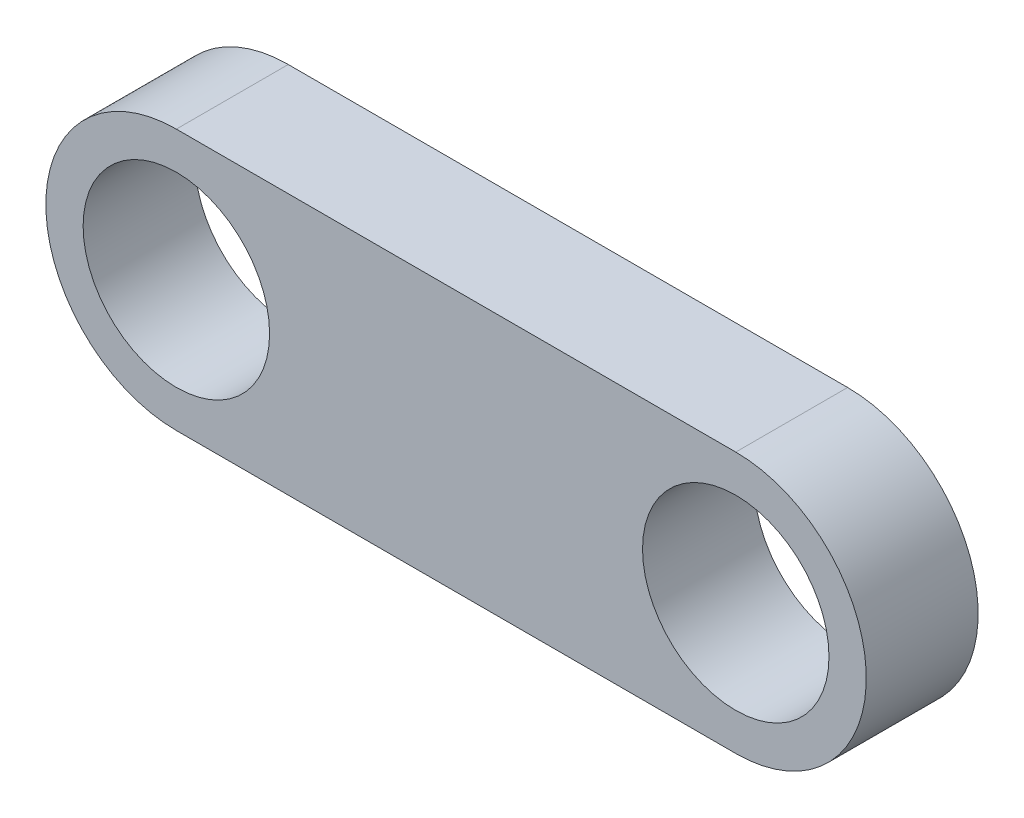
from build123d import *

# Parameters (mm, degrees)
BOSS_EXTRUDE1_DEPTH = 6
SKETCH2_R           = 5
CUT_EXTRUDE1_DEPTH  = 6
SCALE1_SCALE        = 0.3


with BuildPart() as part:
    # Sketch1 → Boss-Extrude1 (new body)
    with BuildSketch(Plane.XY):
        with BuildLine():
            Line((-13.846153846, 7), (16.153846154, 7))
            ThreePointArc((16.153846154, 7), (23.153846154, 0), (16.153846154, -7))
            Line((16.153846154, -7), (-13.846153846, -7))
            ThreePointArc((-13.846153846, -7), (-20.846153846, 0), (-13.846153846, 7))
        make_face()
    extrude(amount=BOSS_EXTRUDE1_DEPTH)

    # Sketch2 → Cut-Extrude1 (cut)
    with BuildSketch(Plane.XY.offset(6)):
        with Locations((-13.846153846, 0)):
            Circle(SKETCH2_R)
        with Locations((16.153846154, 0)):
            Circle(SKETCH2_R)
    extrude(amount=-CUT_EXTRUDE1_DEPTH, mode=Mode.SUBTRACT)


with BuildPart() as part_1:
    # Scale1: scaled about (1.153846154, 0, 3)
    add(part.part.scale(SCALE1_SCALE).moved(Location((0.807692308, 0, 2.1))))


solid = part_1.part
